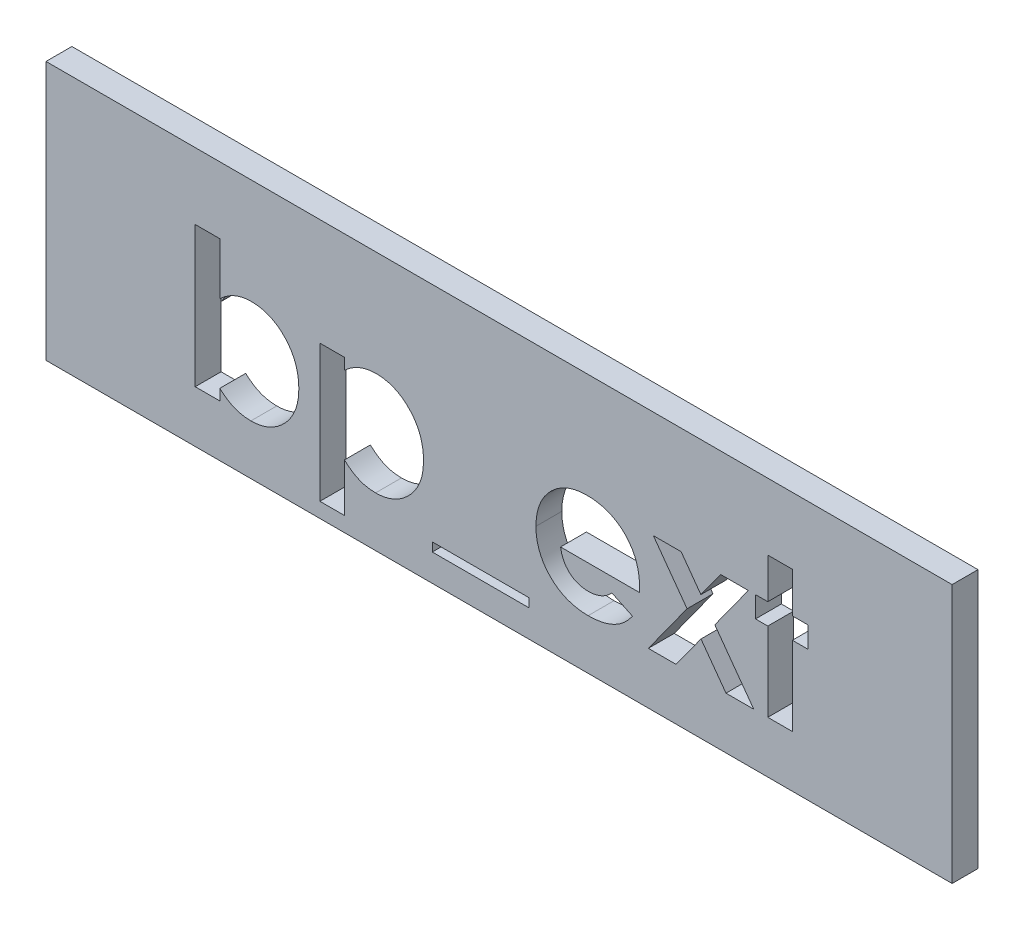
from build123d import *

# Parameters (mm, degrees)
ESQUISSE1_W             = 35
ESQUISSE1_H             = 10
BOSS_EXTRU_1_DEPTH      = 1
ESQUISSE2_R             = 1
BOSS_EXTRU_2_DEPTH      = 3
CHANFREIN1_SIZE         = 0.5
ESQUISSE3_W             = 3.731303419
ESQUISSE3_H             = 0.339209402
ENL_V_MAT_EXTRU_2_DEPTH = 1


with BuildPart() as part:
    # Esquisse1 → Boss.-Extru.1 (new body)
    with BuildSketch(Plane.XY):
        with Locations((17.5, -5)):
            Rectangle(ESQUISSE1_W, ESQUISSE1_H)
    extrude(amount=BOSS_EXTRU_1_DEPTH)

    # Esquisse2 → Boss.-Extru.2 (add)
    with BuildSketch(Plane(origin=(0, 0, 0), x_dir=(-1, 0, 0), z_dir=(0, 0, -1))):
        with Locations(Location((-30, -5, 0), (0, 0, 180))):  # turned: the seam where the file's is
            Circle(ESQUISSE2_R)
        with Locations(Location((-5, -5, 0), (0, 0, 180))):  # turned: the seam where the file's is
            Circle(ESQUISSE2_R)
    extrude(amount=BOSS_EXTRU_2_DEPTH)

    # Chanfrein1
    chanfrein1_edges = [part.edges().sort_by_distance(p)[0] for p in [
        (29, -5, -3),
        (4, -5, -3),
    ]]
    chamfer(chanfrein1_edges, length=CHANFREIN1_SIZE)

    # Esquisse3 → Enlèv. mat.-Extru.2 (cut)
    with BuildSketch(Plane.XY.offset(1)):
        with BuildLine():
            Line((6.713141026, -2.572649573), (6.713141026, -4.583525307))
            add(Edge.make_bspline(
                [(6.713141026, -4.583525307), (6.757244759, -4.541998984), (6.843822735, -4.460480601), (6.98518027, -4.35506841), (7.13160984, -4.266101384), (7.282980265, -4.191462211), (7.440653893, -4.136269762), (7.602693418, -4.09338316), (7.770759214, -4.070669512), (7.884415009, -4.067013922), (7.941715077, -4.06517094)],
                knots=[0, 0, 0, 0, 1.061187343, 2.083167259, 3.083809127, 4.061667593, 5.035358583, 6.007314429, 6.995378812, 8, 8, 8, 8], degree=3))
            add(Edge.make_bspline(
                [(7.941715077, -4.06517094), (8.004001029, -4.066662846), (8.126684142, -4.069601416), (8.307189001, -4.097037187), (8.480170316, -4.141385223), (8.646287709, -4.203307169), (8.804656126, -4.283702473), (8.957054949, -4.379960671), (9.100855881, -4.496053903), (9.236128828, -4.627548954), (9.361259675, -4.771677298), (9.470100466, -4.928375398), (9.560760622, -5.095580805), (9.637599558, -5.271316802), (9.6936797, -5.458497913), (9.736901594, -5.654613228), (9.76098726, -5.861321926), (9.764324411, -6.002139788), (9.766025641, -6.073926616)],
                knots=[0, 0, 0, 0, 0.985987466, 1.942075377, 2.884088208, 3.810275091, 4.743821533, 5.692411115, 6.659945104, 7.665215984, 8.677116751, 9.678438675, 10.680260931, 11.685531812, 12.710472044, 13.769734641, 14.863044265, 16, 16, 16, 16], degree=3))
            add(Edge.make_bspline(
                [(9.766025641, -6.073926616), (9.76441554, -6.14325599), (9.761241677, -6.279919471), (9.735598863, -6.480552708), (9.69213644, -6.672214326), (9.631167468, -6.854973348), (9.553659479, -7.029407327), (9.459055629, -7.195396066), (9.346804073, -7.352359771), (9.218471578, -7.498183983), (9.078249677, -7.630238647), (8.932148507, -7.748717936), (8.777258213, -7.845802422), (8.617450707, -7.927797708), (8.450208414, -7.990497917), (8.276673673, -8.03442646), (8.097121321, -8.063795417), (7.97504759, -8.066479625), (7.913094284, -8.06784188)],
                knots=[0, 0, 0, 0, 1.098553145, 2.165490463, 3.199345634, 4.208780719, 5.21409072, 6.219899742, 7.23156933, 8.267303578, 9.293302409, 10.281606823, 11.243293419, 12.184993323, 13.124258899, 14.066907486, 15.018941492, 16, 16, 16, 16], degree=3))
            add(Edge.make_bspline(
                [(7.913094284, -8.06784188), (7.857907821, -8.0663666), (7.749241662, -8.063461667), (7.589063222, -8.041916446), (7.435137556, -8.005681537), (7.285520218, -7.955767715), (7.139805247, -7.887570758), (6.995455014, -7.802299386), (6.851540512, -7.698874718), (6.760202835, -7.619174108), (6.713141026, -7.578108307)],
                knots=[0, 0, 0, 0, 0.996418773, 1.962021009, 2.912343664, 3.848616743, 4.805003894, 5.811808768, 6.872532775, 8, 8, 8, 8], degree=3))
            Line((6.713141026, -7.578108307), (6.713141026, -8))
            Line((6.713141026, -8), (5.763354701, -8))
            Line((5.763354701, -8), (5.763354701, -2.572649573))
            Line((5.763354701, -2.572649573), (6.713141026, -2.572649573))
        make_face()
        with BuildLine():
            add(Edge.make_bspline(
                [(7.736069378, -4.947115385), (7.697524215, -4.948300675), (7.621954743, -4.950624488), (7.511004993, -4.963942252), (7.405878152, -4.988999721), (7.304975851, -5.021476766), (7.209575803, -5.065315677), (7.118897528, -5.118457449), (7.033717694, -5.181824954), (6.95359422, -5.25290892), (6.881596908, -5.332878514), (6.817633542, -5.418330174), (6.764567409, -5.51037664), (6.720331004, -5.607850774), (6.686956569, -5.711807237), (6.662202407, -5.821361669), (6.64875009, -5.936849805), (6.646467654, -6.015593011), (6.645299145, -6.055906116)],
                knots=[0, 0, 0, 0, 1.060469436, 2.079096586, 3.066888298, 4.028858836, 4.99004353, 5.948472697, 6.914558426, 7.905691313, 8.889602648, 9.869280844, 10.836099585, 11.806137001, 12.808075328, 13.83377171, 14.890985086, 16, 16, 16, 16], degree=3))
            add(Edge.make_bspline(
                [(6.645299145, -6.055906116), (6.646482357, -6.096924734), (6.648804461, -6.177425538), (6.662144636, -6.295376304), (6.686725049, -6.407125617), (6.720802412, -6.512926841), (6.764286076, -6.612793704), (6.817289335, -6.707096426), (6.881956772, -6.793767468), (6.953163167, -6.875845516), (7.033782065, -6.9478806), (7.118578161, -7.012486161), (7.209553773, -7.065707146), (7.305409741, -7.108828725), (7.405418718, -7.14466252), (7.51107103, -7.168875378), (7.62193722, -7.182440126), (7.697518296, -7.18472964), (7.736069378, -7.185897436)],
                knots=[0, 0, 0, 0, 1.117193555, 2.192540452, 3.22680955, 4.227918444, 5.21468246, 6.188555072, 7.166222992, 8.154674427, 9.142376254, 10.104580718, 11.053462639, 12.005072638, 12.963662044, 13.941614018, 14.950094269, 16, 16, 16, 16], degree=3))
            add(Edge.make_bspline(
                [(7.736069378, -7.185897436), (7.773218175, -7.184812589), (7.846751485, -7.182665216), (7.954343175, -7.167681595), (8.057765593, -7.14319687), (8.156208807, -7.10829728), (8.250272078, -7.062858049), (8.340811731, -7.009686628), (8.424701997, -6.943252907), (8.505234031, -6.870236576), (8.577288686, -6.787895155), (8.641930372, -6.70041824), (8.696231309, -6.607025082), (8.739344973, -6.507405975), (8.774988268, -6.403447851), (8.79932307, -6.293247915), (8.812711632, -6.177789782), (8.815051739, -6.099047168), (8.816239316, -6.059086205)],
                knots=[0, 0, 0, 0, 1.021711385, 2.02240246, 2.981887075, 3.941027022, 4.888772411, 5.852236371, 6.822344989, 7.82661704, 8.838806642, 9.826383926, 10.814965113, 11.80282933, 12.807900643, 13.833672313, 14.900613836, 16, 16, 16, 16], degree=3))
            add(Edge.make_bspline(
                [(8.816239316, -6.059086205), (8.815032774, -6.019484756), (8.812655548, -5.941458813), (8.799541155, -5.826962137), (8.774269426, -5.718364319), (8.742360652, -5.614778194), (8.697781233, -5.517552184), (8.645070566, -5.425536121), (8.5830467, -5.338452168), (8.511096343, -5.258651167), (8.432179482, -5.186037989), (8.347937078, -5.121811034), (8.258699957, -5.067135595), (8.163252906, -5.024017819), (8.063848324, -4.988541182), (7.958967102, -4.964104405), (7.849142446, -4.950579726), (7.774266624, -4.948285675), (7.736069378, -4.947115385)],
                knots=[0, 0, 0, 0, 1.094680664, 2.156827393, 3.177782763, 4.17210342, 5.146667393, 6.126451192, 7.099203661, 8.094961544, 9.09004898, 10.058676268, 11.018205477, 11.974998356, 12.947750825, 13.930643515, 14.944335875, 16, 16, 16, 16], degree=3))
        make_face(mode=Mode.SUBTRACT)
        with BuildLine():
            Line((11.52991453, -4.133012821), (11.52991453, -4.568684896))
            add(Edge.make_bspline(
                [(11.52991453, -4.568684896), (11.574008936, -4.528171753), (11.660605798, -4.448608122), (11.80238829, -4.346742923), (11.948091202, -4.259256524), (12.100391671, -4.188889417), (12.257199577, -4.133445707), (12.41992001, -4.09448843), (12.587356642, -4.068795061), (12.701151597, -4.066385185), (12.758488582, -4.06517094)],
                knots=[0, 0, 0, 0, 1.054376801, 2.070687235, 3.070225973, 4.045259405, 5.022040922, 5.996139433, 6.99033025, 8, 8, 8, 8], degree=3))
            add(Edge.make_bspline(
                [(12.758488582, -4.06517094), (12.820774533, -4.066662846), (12.943457647, -4.069601416), (13.123962505, -4.097037187), (13.29694382, -4.141385223), (13.463061213, -4.203307169), (13.62142963, -4.283702473), (13.773828453, -4.379960671), (13.917629385, -4.496053903), (14.052902333, -4.627548954), (14.178033179, -4.771677298), (14.286873971, -4.928375398), (14.377534126, -5.095580805), (14.454373062, -5.271316802), (14.510453205, -5.458497913), (14.553675099, -5.654613228), (14.577760764, -5.861321926), (14.581097916, -6.002139788), (14.582799145, -6.073926616)],
                knots=[0, 0, 0, 0, 0.985987466, 1.942075377, 2.884088208, 3.810275091, 4.743821533, 5.692411115, 6.659945104, 7.665215984, 8.677116751, 9.678438675, 10.680260931, 11.685531812, 12.710472044, 13.769734641, 14.863044265, 16, 16, 16, 16], degree=3))
            add(Edge.make_bspline(
                [(14.582799145, -6.073926616), (14.581189045, -6.14325599), (14.578015181, -6.279919471), (14.552372367, -6.480552708), (14.508909944, -6.672214326), (14.447940972, -6.854973348), (14.370432984, -7.029407327), (14.275829134, -7.195396066), (14.163577578, -7.352359771), (14.035245082, -7.498183983), (13.895023181, -7.630238647), (13.748922011, -7.748717936), (13.594031718, -7.845802422), (13.434224212, -7.927797708), (13.266981919, -7.990497917), (13.093447177, -8.03442646), (12.913894825, -8.063795417), (12.791821094, -8.066479625), (12.729867788, -8.06784188)],
                knots=[0, 0, 0, 0, 1.098553145, 2.165490463, 3.199345634, 4.208780719, 5.21409072, 6.219899742, 7.23156933, 8.267303578, 9.293302409, 10.281606823, 11.243293419, 12.184993323, 13.124258899, 14.066907486, 15.018941492, 16, 16, 16, 16], degree=3))
            add(Edge.make_bspline(
                [(12.729867788, -8.06784188), (12.674660223, -8.066502987), (12.565904641, -8.063865449), (12.405982089, -8.040348446), (12.251495088, -8.005222037), (12.102239282, -7.952352875), (11.956536771, -7.882195943), (11.811906057, -7.794828168), (11.668012702, -7.688093559), (11.576934896, -7.605769171), (11.52991453, -7.563267895)],
                knots=[0, 0, 0, 0, 0.990856396, 1.951927477, 2.896945079, 3.83213376, 4.788585491, 5.796263726, 6.862286081, 8, 8, 8, 8], degree=3))
            Line((11.52991453, -7.563267895), (11.52991453, -9.424679487))
            Line((11.52991453, -9.424679487), (10.580128205, -9.424679487))
            Line((10.580128205, -9.424679487), (10.580128205, -4.133012821))
            Line((10.580128205, -4.133012821), (11.52991453, -4.133012821))
        make_face()
        with BuildLine():
            add(Edge.make_bspline(
                [(12.552842882, -4.947115385), (12.514297719, -4.948300675), (12.438728247, -4.950624488), (12.327778497, -4.963942252), (12.222651656, -4.988999721), (12.121749355, -5.021476766), (12.026349308, -5.065315677), (11.935671033, -5.118457449), (11.850491199, -5.181824954), (11.770367724, -5.25290892), (11.698370412, -5.332878514), (11.634407046, -5.418330174), (11.581340914, -5.51037664), (11.537104509, -5.607850774), (11.503730073, -5.711807237), (11.478975912, -5.821361669), (11.465523594, -5.936849805), (11.463241158, -6.015593011), (11.46207265, -6.055906116)],
                knots=[0, 0, 0, 0, 1.060469436, 2.079096586, 3.066888298, 4.028858836, 4.99004353, 5.948472697, 6.914558426, 7.905691313, 8.889602648, 9.869280844, 10.836099585, 11.806137001, 12.808075328, 13.83377171, 14.890985086, 16, 16, 16, 16], degree=3))
            add(Edge.make_bspline(
                [(11.46207265, -6.055906116), (11.463255861, -6.096924734), (11.465577965, -6.177425538), (11.47891814, -6.295376304), (11.503498553, -6.407125617), (11.537575917, -6.512926841), (11.58105958, -6.612793704), (11.634062839, -6.707096426), (11.698730276, -6.793767468), (11.769936671, -6.875845516), (11.850555569, -6.9478806), (11.935351666, -7.012486161), (12.026327278, -7.065707146), (12.122183245, -7.108828725), (12.222192223, -7.14466252), (12.327844534, -7.168875378), (12.438710724, -7.182440126), (12.514291801, -7.18472964), (12.552842882, -7.185897436)],
                knots=[0, 0, 0, 0, 1.117193555, 2.192540452, 3.22680955, 4.227918444, 5.21468246, 6.188555072, 7.166222992, 8.154674427, 9.142376254, 10.104580718, 11.053462639, 12.005072638, 12.963662044, 13.941614018, 14.950094269, 16, 16, 16, 16], degree=3))
            add(Edge.make_bspline(
                [(12.552842882, -7.185897436), (12.58999168, -7.184812589), (12.663524989, -7.182665216), (12.771116679, -7.167681595), (12.874539098, -7.14319687), (12.972982311, -7.10829728), (13.067045582, -7.062858049), (13.157585235, -7.009686628), (13.241475501, -6.943252907), (13.322007535, -6.870236576), (13.394062191, -6.787895155), (13.458703876, -6.70041824), (13.513004813, -6.607025082), (13.556118477, -6.507405975), (13.591761772, -6.403447851), (13.616096574, -6.293247915), (13.629485137, -6.177789782), (13.631825243, -6.099047168), (13.633012821, -6.059086205)],
                knots=[0, 0, 0, 0, 1.021711385, 2.02240246, 2.981887075, 3.941027022, 4.888772411, 5.852236371, 6.822344989, 7.82661704, 8.838806642, 9.826383926, 10.814965113, 11.80282933, 12.807900643, 13.833672313, 14.900613836, 16, 16, 16, 16], degree=3))
            add(Edge.make_bspline(
                [(13.633012821, -6.059086205), (13.631806278, -6.019484756), (13.629429053, -5.941458813), (13.61631466, -5.826962137), (13.591042931, -5.718364319), (13.559134156, -5.614778194), (13.514554738, -5.517552184), (13.46184407, -5.425536121), (13.399820204, -5.338452168), (13.327869847, -5.258651167), (13.248952987, -5.186037989), (13.164710582, -5.121811034), (13.075473461, -5.067135595), (12.98002641, -5.024017819), (12.880621828, -4.988541182), (12.775740606, -4.964104405), (12.66591595, -4.950579726), (12.591040128, -4.948285675), (12.552842882, -4.947115385)],
                knots=[0, 0, 0, 0, 1.094680664, 2.156827393, 3.177782763, 4.17210342, 5.146667393, 6.126451192, 7.099203661, 8.094961544, 9.09004898, 10.058676268, 11.018205477, 11.974998356, 12.947750825, 13.930643515, 14.944335875, 16, 16, 16, 16], degree=3))
        make_face(mode=Mode.SUBTRACT)
        with Locations((16.787660257, -8.780181624)):
            Rectangle(ESQUISSE3_W, ESQUISSE3_H)
        with BuildLine():
            Line((22.924170339, -6.303952991), (19.874465812, -6.303952991))
            add(Edge.make_bspline(
                [(19.874465812, -6.303952991), (19.880683913, -6.339388828), (19.892902973, -6.409023042), (19.919437095, -6.510172781), (19.953298615, -6.605494587), (19.993879513, -6.695115884), (20.040495598, -6.779510462), (20.094869398, -6.858282479), (20.156311232, -6.931362358), (20.22446586, -6.998432487), (20.298197267, -7.058528775), (20.377147884, -7.111176923), (20.461399183, -7.154345184), (20.549985254, -7.190731548), (20.643568039, -7.219553234), (20.742285268, -7.239431004), (20.845875258, -7.251172875), (20.916443923, -7.252871202), (20.952515692, -7.253739316)],
                knots=[0, 0, 0, 0, 1.091296461, 2.144483647, 3.168565212, 4.157007626, 5.126487748, 6.090021542, 7.05641414, 8.019231907, 8.98705074, 9.938580405, 10.892824166, 11.854447369, 12.841318655, 13.858982407, 14.905600794, 16, 16, 16, 16], degree=3))
            add(Edge.make_bspline(
                [(20.952515692, -7.253739316), (20.996056765, -7.25258979), (21.081801962, -7.250326034), (21.207419313, -7.23024988), (21.328909589, -7.199925733), (21.445123066, -7.15483118), (21.557405893, -7.098696389), (21.66390955, -7.028759346), (21.766477532, -6.947063841), (21.829056088, -6.884092976), (21.860960871, -6.851988181)],
                knots=[0, 0, 0, 0, 1.021034703, 2.010718019, 2.977989445, 3.954245119, 4.929443971, 5.918328161, 6.938689359, 8, 8, 8, 8], degree=3))
            Line((21.860960871, -6.851988181), (22.655982906, -7.23041867))
            add(Edge.make_bspline(
                [(22.655982906, -7.23041867), (22.630952101, -7.2650074), (22.581354482, -7.333543698), (22.500388033, -7.42999197), (22.415894388, -7.51998212), (22.327810532, -7.602922269), (22.236024752, -7.678576072), (22.140792374, -7.747865128), (22.040721616, -7.808929053), (21.937813374, -7.864722083), (21.829940345, -7.91255319), (21.717401062, -7.953341869), (21.60067219, -7.990214488), (21.478279697, -8.018309404), (21.351242744, -8.04054911), (21.219257434, -8.056342248), (21.082341161, -8.066096912), (20.989279968, -8.067253315), (20.941915398, -8.06784188)],
                knots=[0, 0, 0, 0, 1.028154879, 2.037251081, 3.030720504, 4.000128189, 4.949298328, 5.894184978, 6.834267904, 7.770992897, 8.712077017, 9.673380525, 10.653304757, 11.658697181, 12.695551717, 13.758623199, 14.859225354, 16, 16, 16, 16], degree=3))
            add(Edge.make_bspline(
                [(20.941915398, -8.06784188), (20.869045784, -8.066356288), (20.726334845, -8.063446841), (20.517594299, -8.036443012), (20.319348676, -7.991667753), (20.131038201, -7.930802664), (19.953476876, -7.85044168), (19.786576826, -7.752153529), (19.62867048, -7.637822594), (19.48458276, -7.505049371), (19.353314596, -7.360533612), (19.238016802, -7.205333555), (19.141537251, -7.040533524), (19.062306302, -6.867224201), (19.000725257, -6.684961981), (18.956328895, -6.49366733), (18.929113393, -6.293431612), (18.926173984, -6.157048736), (18.924679487, -6.087706998)],
                knots=[0, 0, 0, 0, 1.103565453, 2.161269334, 3.182010356, 4.179077853, 5.15417608, 6.128274628, 7.109042802, 8.101804412, 9.090965879, 10.063106201, 11.02526161, 11.978650795, 12.945248442, 13.93468508, 14.949922959, 16, 16, 16, 16], degree=3))
            add(Edge.make_bspline(
                [(18.924679487, -6.087706998), (18.926188693, -6.016603197), (18.929157987, -5.876709662), (18.95609457, -5.67185041), (19.000847997, -5.476386975), (19.062609181, -5.290050184), (19.140638186, -5.112257255), (19.238345275, -4.944563662), (19.35325738, -4.786385588), (19.484052653, -4.638463007), (19.628750773, -4.504946716), (19.782506197, -4.385957019), (19.947046523, -4.286806905), (20.12051066, -4.206693674), (20.301789068, -4.141603697), (20.492977071, -4.098291753), (20.692620022, -4.069210375), (20.829091547, -4.066532162), (20.898454193, -4.06517094)],
                knots=[0, 0, 0, 0, 1.079208495, 2.12329425, 3.130605359, 4.119693003, 5.099659317, 6.073216462, 7.060498243, 8.06384408, 9.066070512, 10.045757761, 11.010926815, 11.975797609, 12.942977511, 13.929384301, 14.947594487, 16, 16, 16, 16], degree=3))
            add(Edge.make_bspline(
                [(20.898454193, -4.06517094), (20.971672902, -4.06667958), (21.115430291, -4.06964164), (21.325624651, -4.096426204), (21.525186601, -4.141474498), (21.714966386, -4.201813297), (21.892540441, -4.284204284), (22.061810606, -4.380073719), (22.218716823, -4.496876004), (22.364931544, -4.628999478), (22.496920213, -4.775585892), (22.612292934, -4.934823635), (22.71046092, -5.105158639), (22.790027046, -5.287281648), (22.85154486, -5.480645912), (22.895982318, -5.68500031), (22.922990231, -5.901122106), (22.925874944, -6.049113087), (22.927350427, -6.124808026)],
                knots=[0, 0, 0, 0, 1.080001299, 2.120471247, 3.119684163, 4.095710327, 5.052285597, 6.002875087, 6.961153713, 7.931888285, 8.906493152, 9.865905668, 10.82813294, 11.801621613, 12.7925306, 13.817193356, 14.883530496, 16, 16, 16, 16], degree=3))
            Line((22.927350427, -6.124808026), (22.924170339, -6.303952991))
        make_face()
        with BuildLine():
            add(Edge.make_bspline(
                [(21.977564103, -5.557692308), (21.959641054, -5.509325259), (21.924005364, -5.413158967), (21.843505823, -5.280472948), (21.736685508, -5.165561468), (21.612445818, -5.063829422), (21.470494193, -4.98125734), (21.315303778, -4.921472471), (21.148836148, -4.885624713), (21.034315389, -4.881420401), (20.975836338, -4.879273504)],
                knots=[0, 0, 0, 0, 0.954238005, 1.897273737, 2.851915805, 3.847685534, 4.862635127, 5.880135777, 6.917509367, 8, 8, 8, 8], degree=3))
            add(Edge.make_bspline(
                [(20.975836338, -4.879273504), (20.911967693, -4.88133586), (20.78711779, -4.885367335), (20.607030306, -4.928243552), (20.437158288, -4.992235026), (20.337011374, -5.058211595), (20.286817241, -5.09127938)],
                knots=[0, 0, 0, 0, 1.044195649, 2.041185066, 3.018232172, 4, 4, 4, 4], degree=3))
            add(Edge.make_bspline(
                [(20.286817241, -5.09127938), (20.25549985, -5.11646453), (20.188732775, -5.170157982), (20.102022182, -5.277271321), (20.016611526, -5.40696153), (19.968050859, -5.505470405), (19.942307692, -5.557692308)],
                knots=[0, 0, 0, 0, 0.82159062, 1.751589201, 2.808063854, 4, 4, 4, 4], degree=3))
            Line((19.942307692, -5.557692308), (21.977564103, -5.557692308))
        make_face(mode=Mode.SUBTRACT)
        Polygon((23.460545206, -4.133012821), (24.532234909, -4.133012821), (25.296516092, -5.186682025), (26.057617187, -4.133012821), (27.129306891, -4.133012821), (25.833950988, -5.927642561), (27.33707265, -8), (26.265382946, -8), (25.299696181, -6.668603098), (24.338249533, -8), (23.266559829, -8), (24.762261285, -5.927642561), align=None)
        Polygon((27.879807692, -2.572649573), (28.829594017, -2.572649573), (28.829594017, -4.133012821), (29.44017094, -4.133012821), (29.44017094, -4.947115385), (28.829594017, -4.947115385), (28.829594017, -8), (27.879807692, -8), (27.879807692, -4.947115385), (27.40491453, -4.947115385), (27.40491453, -4.133012821), (27.879807692, -4.133012821), align=None)
    extrude(amount=-ENL_V_MAT_EXTRU_2_DEPTH, mode=Mode.SUBTRACT)


with BuildPart() as body_2:
    # of the pieces the cut leaves, the one that is kept (enl_v_mat_extru_2_keep)
    add(part.part.solids().sort_by_distance((31, -5, -2.5))[0])


solid = body_2.part
